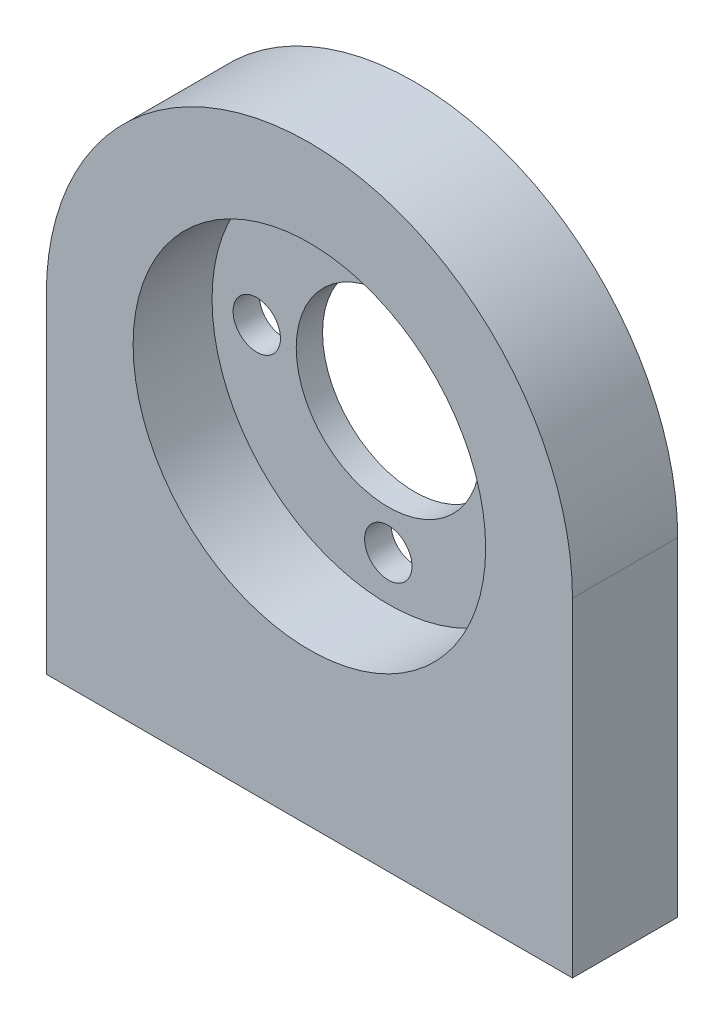
from build123d import *

# Parameters (mm, degrees)
ESQUISSE1_R             = 7
ESQUISSE1_R_2           = 1.8
BOSS_EXTRU_1_DEPTH      = 8
ESQUISSE2_R             = 13.4
ENL_V_MAT_EXTRU_1_DEPTH = 6
ESQUISSE3_R             = 2
ENL_V_MAT_EXTRU_2_DEPTH = 12
CHANFREIN1_SIZE         = 1


with BuildPart() as part:
    # Esquisse1 → Boss.-Extru.1 (new body)
    with BuildSketch(Plane.XY):
        with BuildLine():
            Line((-20, 0), (-20, -25))
            Line((-20, -25), (20, -25))
            Line((20, -25), (20, 0))
            ThreePointArc((20, 0), (0, 20), (-20, 0))
        make_face()
        Circle(ESQUISSE1_R, mode=Mode.SUBTRACT)
        with Locations((0, 10)):
            Circle(ESQUISSE1_R_2, mode=Mode.SUBTRACT)
        with Locations((10, 0)):
            Circle(ESQUISSE1_R_2, mode=Mode.SUBTRACT)
        with Locations((0, -10)):
            Circle(ESQUISSE1_R_2, mode=Mode.SUBTRACT)
        with Locations((-10, 0)):
            Circle(ESQUISSE1_R_2, mode=Mode.SUBTRACT)
    extrude(amount=BOSS_EXTRU_1_DEPTH)

    # Esquisse2 → Enlèv. mat.-Extru.1 (cut)
    with BuildSketch(Plane.XY.offset(8)):
        Circle(ESQUISSE2_R)
    extrude(amount=-ENL_V_MAT_EXTRU_1_DEPTH, mode=Mode.SUBTRACT)

    # Esquisse3 → Enlèv. mat.-Extru.2 (cut)
    with BuildSketch(Plane.XZ.offset(25)):
        with Locations((-15, 4)):
            Circle(ESQUISSE3_R)
        with Locations((15, 4)):
            Circle(ESQUISSE3_R)
    extrude(amount=-ENL_V_MAT_EXTRU_2_DEPTH, mode=Mode.SUBTRACT)

    # Chanfrein1
    chanfrein1_edges = [part.edges().sort_by_distance(p)[0] for p in [
        (-17, -25, 4),
        (13, -25, 4),
    ]]
    chamfer(chanfrein1_edges, length=CHANFREIN1_SIZE)


solid = part.part
